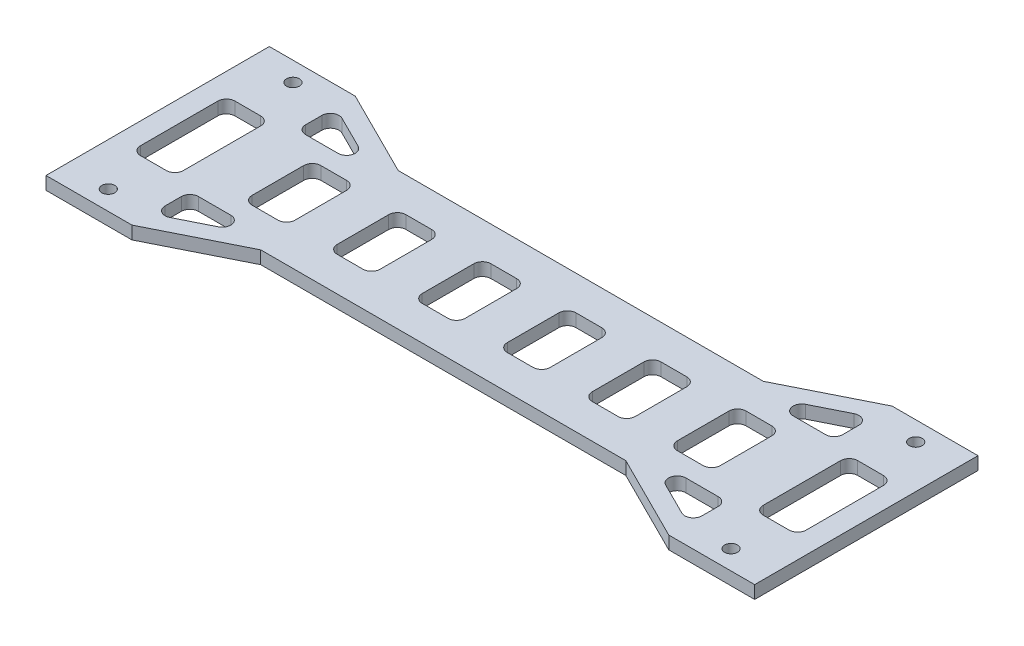
from build123d import *

# Parameters (mm, degrees)
EXTRUDE_2_DEPTH       = 3
HOLE_WIZARD_3_0_3_6_D = 3
SKETCH_9_W            = 10
SKETCH_9_H            = 22
SKETCH_9_H_2          = 16
CUT_EXTRUDE_1_DEPTH   = 3
FILLET_1_R            = 2


with BuildPart() as part:
    # 草图1 → 凸台-拉伸2 (new body)
    with BuildSketch(Plane(origin=(0, 0, 0), x_dir=(1, 0, 0), z_dir=(0, 1, 0))):
        Polygon((-82.5, 26), (-62.5, 26), (-42.5, 16), (42.5, 16), (62.5, 26), (82.5, 26), (82.5, -26), (62.5, -26), (42.5, -16), (-42.5, -16), (-62.5, -26), (-82.5, -26), align=None)
    extrude(amount=EXTRUDE_2_DEPTH)

    # Ø3.0 (3) 直径孔6 (through all)
    with Locations(Plane(origin=(-72.5, 3, -21.5), x_dir=(0, 0, 1), z_dir=(0, 1, 0))):
        with Locations((0, 0), (0, 145), (43, 145), (43, 0)):
            Hole(HOLE_WIZARD_3_0_3_6_D / 2)

    # 草图9 → 切除-拉伸1 (cut)
    with BuildSketch(Plane(origin=(0, 3, 0), x_dir=(1, 0, 0), z_dir=(0, 1, 0))):
        with Locations((-72.5, 0)):
            Rectangle(SKETCH_9_W, SKETCH_9_H)
        with Locations((72.5, 0)):
            Rectangle(SKETCH_9_W, SKETCH_9_H)
        Polygon((-62.5, 21.455387521), (-62.5, 12.455387521), (-44.5, 12.455387521), align=None)
        Polygon((44.5, 12.5), (62.5, 21.5), (62.5, 12.5), align=None)
        Polygon((62.5, -12.5), (44.5, -12.5), (62.5, -21.5), align=None)
        Polygon((-44.5, -12.5), (-62.5, -21.5), (-62.5, -12.5), align=None)
        with Locations((-49.5, 0)):
            Rectangle(SKETCH_9_W, SKETCH_9_H_2)
        with Locations((-29.7, 0)):
            Rectangle(SKETCH_9_W, SKETCH_9_H_2)
        with Locations((-9.9, 0)):
            Rectangle(SKETCH_9_W, SKETCH_9_H_2)
        with Locations((29.7, 0)):
            Rectangle(SKETCH_9_W, SKETCH_9_H_2)
        with Locations((49.5, 0)):
            Rectangle(SKETCH_9_W, SKETCH_9_H_2)
        with Locations((9.9, 0)):
            Rectangle(SKETCH_9_W, SKETCH_9_H_2)
    extrude(amount=-CUT_EXTRUDE_1_DEPTH, mode=Mode.SUBTRACT)

    # 圆角1
    fillet_1_edges = [part.edges().sort_by_distance(p)[0] for p in [
        (62.5, 1.5, 21.5),
        (-44.5, 1.5, -12.455387521),
        (-62.5, 1.5, -12.455387521),
        (44.5, 1.5, 12.5),
        (44.5, 1.5, -12.5),
        (62.5, 1.5, -12.5),
        (62.5, 1.5, -21.5),
        (-44.5, 1.5, 12.5),
        (62.5, 1.5, 12.5),
        (77.5, 1.5, -11),
        (34.7, 1.5, -8),
        (14.9, 1.5, -8),
        (-4.9, 1.5, -8),
        (-24.7, 1.5, -8),
        (-44.5, 1.5, -8),
        (-67.5, 1.5, -11),
        (-44.5, 1.5, 8),
        (-67.5, 1.5, 11),
        (-4.9, 1.5, 8),
        (34.7, 1.5, 8),
        (54.5, 1.5, 8),
        (77.5, 1.5, 11),
        (44.5, 1.5, 8),
        (67.5, 1.5, 11),
        (24.7, 1.5, 8),
        (4.9, 1.5, 8),
        (-14.9, 1.5, 8),
        (-34.7, 1.5, 8),
        (-77.5, 1.5, 11),
        (-62.5, 1.5, 21.5),
        (-54.5, 1.5, 8),
        (67.5, 1.5, -11),
        (44.5, 1.5, -8),
        (24.7, 1.5, -8),
        (4.9, 1.5, -8),
        (-14.9, 1.5, -8),
        (-62.5, 1.5, 12.5),
        (-34.7, 1.5, -8),
        (-54.5, 1.5, -8),
        (-62.5, 1.5, -21.455387521),
        (-77.5, 1.5, -11),
        (54.5, 1.5, -8),
        (14.9, 1.5, 8),
        (-24.7, 1.5, 8),
    ]]
    fillet(fillet_1_edges, radius=FILLET_1_R)


solid = part.part
